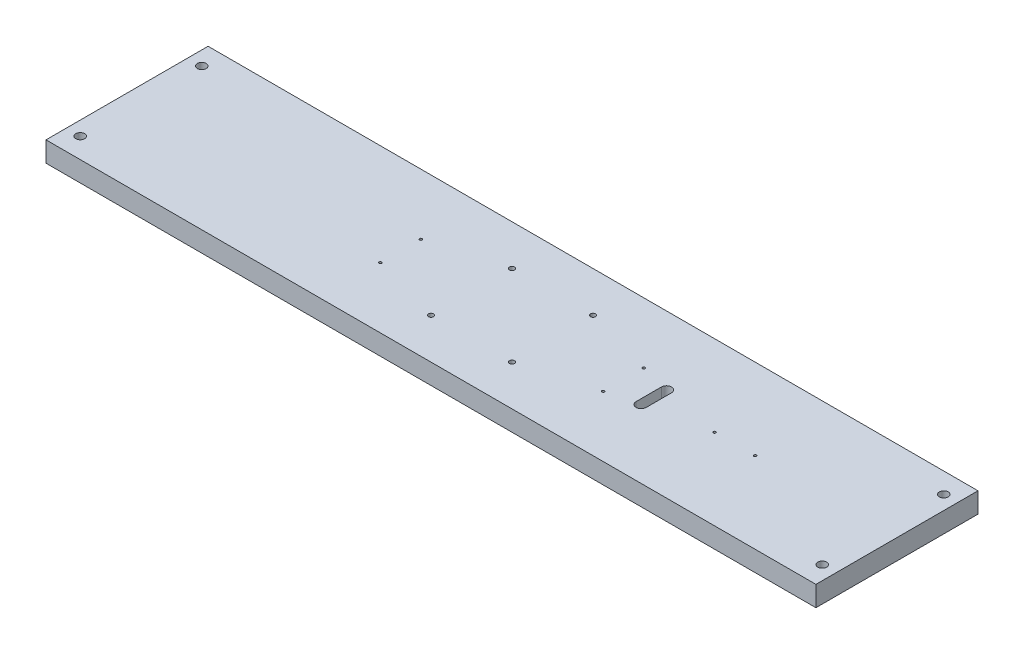
from build123d import *

# Parameters (mm, degrees)
SKETCH1_W           = 482.6
SKETCH1_H           = 101.6
BOSS_EXTRUDE1_DEPTH = 12.7
SKETCH2_R           = 2.7813
CUT_EXTRUDE1_DEPTH  = 13.7
SKETCH3_R           = 1.5875
CUT_EXTRUDE2_DEPTH  = 13.7
SKETCH4_R           = 0.79375
CUT_EXTRUDE3_DEPTH  = 13.7
SKETCH5_R           = 0.79375
CUT_EXTRUDE4_DEPTH  = 13.7
CUT_EXTRUDE5_DEPTH  = 13.7


with BuildPart() as part:
    # Sketch1 → Boss-Extrude1 (new body)
    with BuildSketch(Plane(origin=(0, 0, 0), x_dir=(1, 0, 0), z_dir=(0, 1, 0))):
        Rectangle(SKETCH1_W, SKETCH1_H)
    extrude(amount=BOSS_EXTRUDE1_DEPTH)

    # Sketch2 → Cut-Extrude1 (cut, through all)
    with BuildSketch(Plane(origin=(0, 12.7, 0), x_dir=(1, 0, 0), z_dir=(0, 1, 0))):
        with Locations((-232.5624, 38.1)):
            Circle(SKETCH2_R)
        with Locations((-232.5624, -38.1)):
            Circle(SKETCH2_R)
        with Locations((232.5624, 38.1)):
            Circle(SKETCH2_R)
        with Locations((232.5624, -38.1)):
            Circle(SKETCH2_R)
    extrude(amount=-CUT_EXTRUDE1_DEPTH, mode=Mode.SUBTRACT)

    # Sketch3 → Cut-Extrude2 (cut, through all)
    with BuildSketch(Plane(origin=(0, 12.7, 0), x_dir=(1, 0, 0), z_dir=(0, 1, 0))):
        with Locations((-25.4, 25.4)):
            Circle(SKETCH3_R)
        with Locations((25.4, 25.4)):
            Circle(SKETCH3_R)
        with Locations((25.4, -25.4)):
            Circle(SKETCH3_R)
        with Locations((-25.4, -25.4)):
            Circle(SKETCH3_R)
    extrude(amount=-CUT_EXTRUDE2_DEPTH, mode=Mode.SUBTRACT)

    # Sketch4 → Cut-Extrude3 (cut, through all)
    with BuildSketch(Plane(origin=(0, 12.7, 0), x_dir=(1, 0, 0), z_dir=(0, 1, 0))):
        with Locations((-69.85, 12.7)):
            Circle(SKETCH4_R)
        with Locations((-69.85, -12.7)):
            Circle(SKETCH4_R)
        with Locations((69.85, -12.7)):
            Circle(SKETCH4_R)
        with Locations((69.85, 12.7)):
            Circle(SKETCH4_R)
    extrude(amount=-CUT_EXTRUDE3_DEPTH, mode=Mode.SUBTRACT)

    # Sketch5 → Cut-Extrude4 (cut, through all)
    with BuildSketch(Plane(origin=(0, 12.7, 0), x_dir=(1, 0, 0), z_dir=(0, 1, 0))):
        with Locations((127, 0)):
            Circle(SKETCH5_R)
        with Locations((152.4, 0)):
            Circle(SKETCH5_R)
    extrude(amount=-CUT_EXTRUDE4_DEPTH, mode=Mode.SUBTRACT)

    # Sketch6 → Cut-Extrude5 (cut, through all)
    with BuildSketch(Plane(origin=(0, 12.7, 0), x_dir=(1, 0, 0), z_dir=(0, 1, 0))):
        with BuildLine():
            Line((85.725, 7.9375), (85.725, -7.9375))
            ThreePointArc((85.725, -7.9375), (88.9, -11.1125), (92.075, -7.9375))
            Line((92.075, -7.9375), (92.075, 7.9375))
            ThreePointArc((92.075, 7.9375), (88.9, 11.1125), (85.725, 7.9375))
        make_face()
    extrude(amount=-CUT_EXTRUDE5_DEPTH, mode=Mode.SUBTRACT)


solid = part.part
